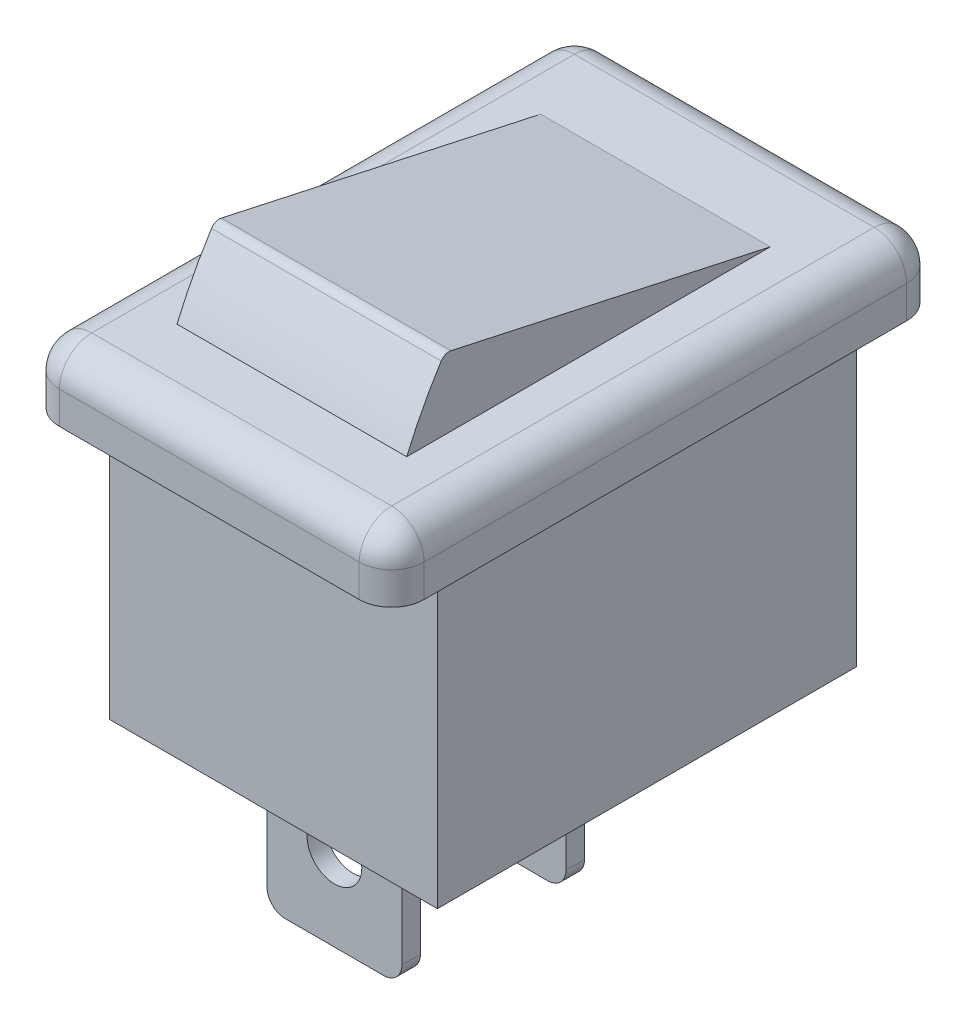
from build123d import *

# Parameters (mm, degrees)
BOSS_EXTRUDE1_DEPTH = 4.5
SKETCH2_W           = 10
SKETCH2_H           = 15.0114
BOSS_EXTRUDE2_DEPTH = 1.778
FILLET1_R           = 0.889
SKETCH3_W           = 3.7
SKETCH3_H           = 0.508
BOSS_EXTRUDE3_DEPTH = 4
FILLET2_R           = 0.5
SKETCH4_R           = 0.75
CUT_EXTRUDE1_DEPTH  = 12.5797
BOSS_EXTRUDE4_DEPTH = 3.15


with BuildPart() as part:
    # Sketch1 → Boss-Extrude1 (new body, symmetric)
    with BuildSketch(Plane(origin=(0, 0, 0), x_dir=(0, 0, -1), z_dir=(1, 0, 0))):
        Polygon((-5.75, 0), (-5.75, -8.0264), (5.75, -8.0264), (5.75, 0), (7.5057, 0), (7.5057, 1.778), (-7.5057, 1.778), (-7.5057, 0), align=None)
    extrude(amount=BOSS_EXTRUDE1_DEPTH, both=True)

    # Sketch2 → Boss-Extrude2 (add)
    with BuildSketch(Plane(origin=(0, 1.778, 0), x_dir=(1, 0, 0), z_dir=(0, 1, 0))):
        Rectangle(SKETCH2_W, SKETCH2_H)
    extrude(amount=-BOSS_EXTRUDE2_DEPTH)

    # Fillet1
    fillet1_edges = [part.edges().sort_by_distance(p)[0] for p in [
        (0, 1.778, 7.5057),
        (0, 1.778, -7.5057),
        (5, 0.889, 7.5057),
        (5, 1.778, 0),
        (5, 0.889, -7.5057),
        (-5, 0.889, 7.5057),
        (-5, 0.889, -7.5057),
        (-5, 1.778, 0),
    ]]
    fillet(fillet1_edges, radius=FILLET1_R)

    # Sketch3 → Boss-Extrude3 (add)
    with BuildSketch(Plane.XZ.offset(8.0264)):
        with Locations((0, 3.82)):
            Rectangle(SKETCH3_W, SKETCH3_H)
        with Locations((0, -0.68)):
            Rectangle(SKETCH3_W, SKETCH3_H)
    extrude(amount=BOSS_EXTRUDE3_DEPTH)

    # Fillet2
    fillet2_edges = [part.edges().sort_by_distance(p)[0] for p in [
        (1.85, -12.0264, 3.82),
        (-1.85, -12.0264, 3.82),
        (1.85, -12.0264, -0.68),
        (-1.85, -12.0264, -0.68),
    ]]
    fillet(fillet2_edges, radius=FILLET2_R)

    # Sketch4 → Cut-Extrude1 (cut, through all)
    with BuildSketch(Plane.XY.offset(4.074)):
        with Locations((0, -9.7764)):
            Circle(SKETCH4_R)
    extrude(amount=-CUT_EXTRUDE1_DEPTH, mode=Mode.SUBTRACT)

    # Sketch5 → Boss-Extrude4 (add, symmetric)
    with BuildSketch(Plane(origin=(0, 0, 0), x_dir=(0, 0, -1), z_dir=(1, 0, 0))):
        with BuildLine():
            Line((4.734, 1.778), (-4.028021931, 3.690536137))
            ThreePointArc((-4.028021931, 3.690536137), (-4.179670828, 3.676927945), (-4.29629138, 3.579039143))
            ThreePointArc((-4.29629138, 3.579039143), (-4.807252645, 2.698529173), (-5.242, 1.778))
            Line((-5.242, 1.778), (4.734, 1.778))
        make_face()
    extrude(amount=BOSS_EXTRUDE4_DEPTH, both=True)


solid = part.part
